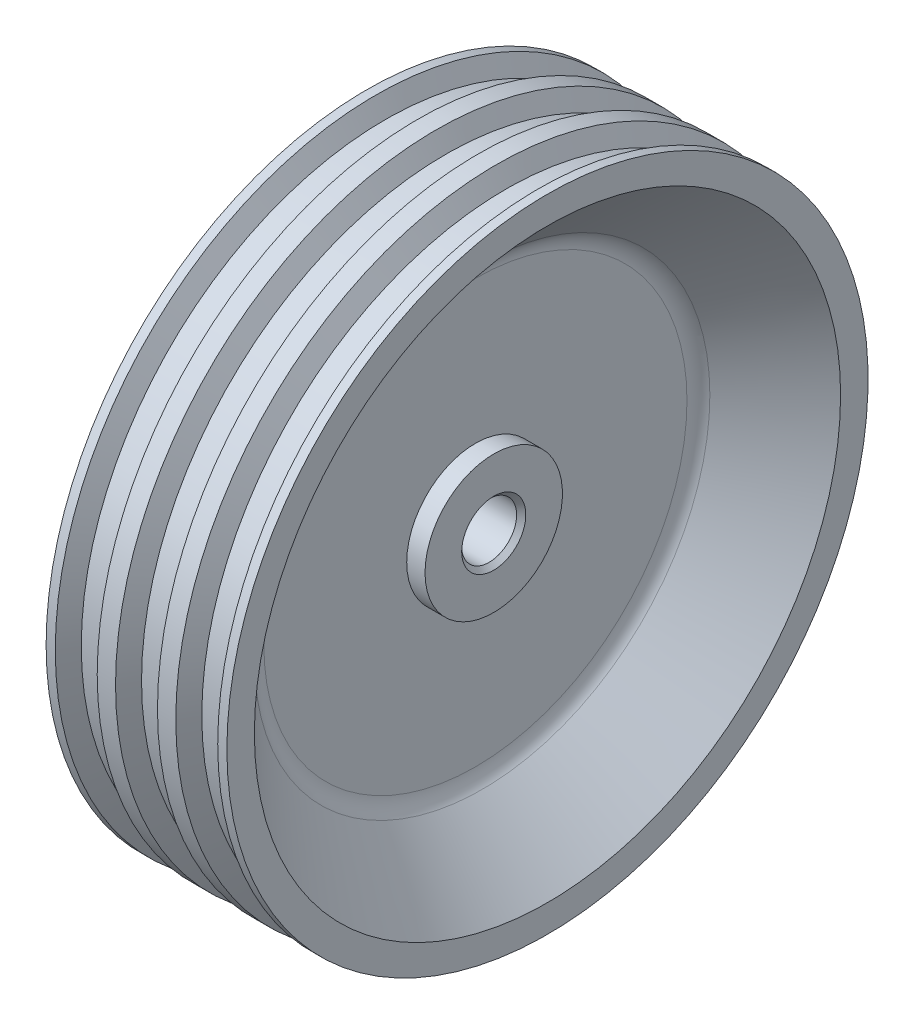
from build123d import *

# Parameters (mm, degrees)
OTW_R_12_0_12_1_D = 12
ZAOKR_GLENIE1_R   = 5
ZAOKR_GLENIE2_R   = 5
SFAZOWANIE1_SIZE  = 1


with BuildPart() as part:
    # Szkic2 → Obrót1 (revolve)
    with BuildSketch(Plane(origin=(0, 0, 0), x_dir=(1, 0, 0), z_dir=(0, 1, 0)), mode=Mode.PRIVATE) as obr_t1_sk:
        Polygon((-8, 0), (-8, 15), (-4, 15), (-4, 48.264617093), (-19.735382907, 64), (-19.735382907, 70), (-17.735382907, 70), (-15.656921938, 66.4), (-10.656921938, 66.4), (-8.578460969, 70), (-4.578460969, 70), (-2.5, 66.4), (2.5, 66.4), (4.578460969, 70), (8.578460969, 70), (10.656921938, 66.4), (15.656921938, 66.4), (17.735382907, 70), (19.735382907, 70), (19.735382907, 64), (4, 48.264617093), (4, 15), (8, 15), (8, 0), align=None)
    revolve(obr_t1_sk.sketch.rotate(Axis((-13.757967627, 0, 0), (1, 0, 0)), 180), axis=Axis((-13.757967627, 0, 0), (1, 0, 0)))  # turned: the seam where the file's is

    # Otwór Ø12.0 (12)1 (through all)
    with Locations(Plane(origin=(8, 0, 0), x_dir=(0, 0, -1), z_dir=(1, 0, 0))):
        with Locations((0, 0)):
            Hole(OTW_R_12_0_12_1_D / 2)

    # Zaokrąglenie1
    zaokr_glenie1_edges = [part.edges().sort_by_distance(p)[0] for p in [
        (4, 0, -48.264617093),
    ]]
    fillet(zaokr_glenie1_edges, radius=ZAOKR_GLENIE1_R)

    # Zaokrąglenie2
    zaokr_glenie2_edges = [part.edges().sort_by_distance(p)[0] for p in [
        (-4, 0, -48.264617093),
    ]]
    fillet(zaokr_glenie2_edges, radius=ZAOKR_GLENIE2_R)

    # Sfazowanie1
    sfazowanie1_edges = [part.edges().sort_by_distance(p)[0] for p in [
        (-8, 0, -6),
        (8, 0, -6),
    ]]
    chamfer(sfazowanie1_edges, length=SFAZOWANIE1_SIZE)


solid = part.part
